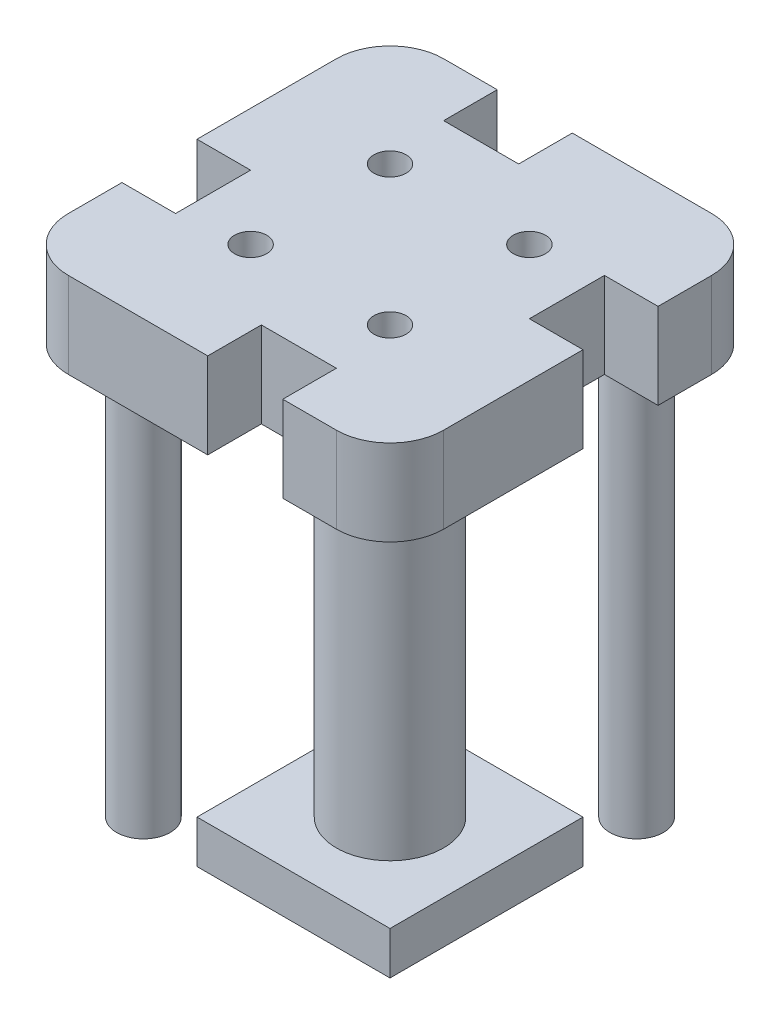
from build123d import *

# Parameters (mm, degrees)
SKETCH1_W           = 35
SKETCH1_H           = 35
BOSS_EXTRUDE1_DEPTH = 8
SKETCH2_W           = 7
SKETCH2_H           = 5
SKETCH2_W_2         = 5
SKETCH2_H_2         = 7
SKETCH2_R           = 1.5
CUT_EXTRUDE1_DEPTH  = 51.139804547
SKETCH2_5_R         = 4
SKETCH2_5_R_2       = 1.5
CUT_EXTRUDE2_DEPTH  = 4
SKETCH2_7_R         = 2.5
SKETCH2_7_R_2       = 5
BOSS_EXTRUDE2_DEPTH = 38.25
SKETCH3_W           = 18
SKETCH3_H           = 18
BOSS_EXTRUDE3_DEPTH = 4
FILLET1_R           = 5


with BuildPart() as part:
    # Sketch1 → Boss-Extrude1 (new body)
    with BuildSketch(Plane(origin=(0, 0, 0), x_dir=(1, 0, 0), z_dir=(0, 1, 0))):
        with Locations((17.5, 17.5)):
            Rectangle(SKETCH1_W, SKETCH1_H)
    extrude(amount=BOSS_EXTRUDE1_DEPTH)

    # Sketch2 → Cut-Extrude1 (cut, through all)
    with BuildSketch(Plane.XZ):
        with Locations((21.5, -2.5)):
            Rectangle(SKETCH2_W, SKETCH2_H)
        with Locations((2.5, -13.5)):
            Rectangle(SKETCH2_W_2, SKETCH2_H_2)
        with Locations((32.5, -21.5)):
            Rectangle(SKETCH2_W_2, SKETCH2_H_2)
        with Locations((13.5, -32.5)):
            Rectangle(SKETCH2_W, SKETCH2_H)
        with Locations((11, -11)):
            Circle(SKETCH2_R)
        with Locations((24, -11)):
            Circle(SKETCH2_R)
        with Locations((24, -24)):
            Circle(SKETCH2_R)
        with Locations((11, -24)):
            Circle(SKETCH2_R)
    extrude(amount=-CUT_EXTRUDE1_DEPTH, mode=Mode.SUBTRACT)

    # Sketch2_5 → Cut-Extrude2 (cut)
    with BuildSketch(Plane.XZ):
        with Locations((29, -6)):
            Circle(SKETCH2_5_R)
        with Locations((6, -29)):
            Circle(SKETCH2_5_R)
        with Locations((11, -11)):
            Circle(SKETCH2_5_R_2)
    extrude(amount=-CUT_EXTRUDE2_DEPTH, mode=Mode.SUBTRACT)

    # Sketch2_7 → Boss-Extrude2 (add)
    with BuildSketch(Plane.XZ):
        with Locations((6, -6)):
            Circle(SKETCH2_7_R)
        with Locations((29, -29)):
            Circle(SKETCH2_7_R)
        with Locations((17.5, -17.5)):
            Circle(SKETCH2_7_R_2)
    extrude(amount=BOSS_EXTRUDE2_DEPTH)

    # Sketch3 → Boss-Extrude3 (add)
    with BuildSketch(Plane(origin=(0, -38.25, 0), x_dir=(-1, 0, 0), z_dir=(0, -1, 0))):
        with Locations((-17.5, 17.5)):
            Rectangle(SKETCH3_W, SKETCH3_H)
    extrude(amount=BOSS_EXTRUDE3_DEPTH)

    # Fillet1
    fillet1_edges = [part.edges().sort_by_distance(p)[0] for p in [
        (35, 4, -35),
        (0, 4, -35),
        (0, 4, 0),
        (35, 4, 0),
    ]]
    fillet(fillet1_edges, radius=FILLET1_R)


solid = part.part
